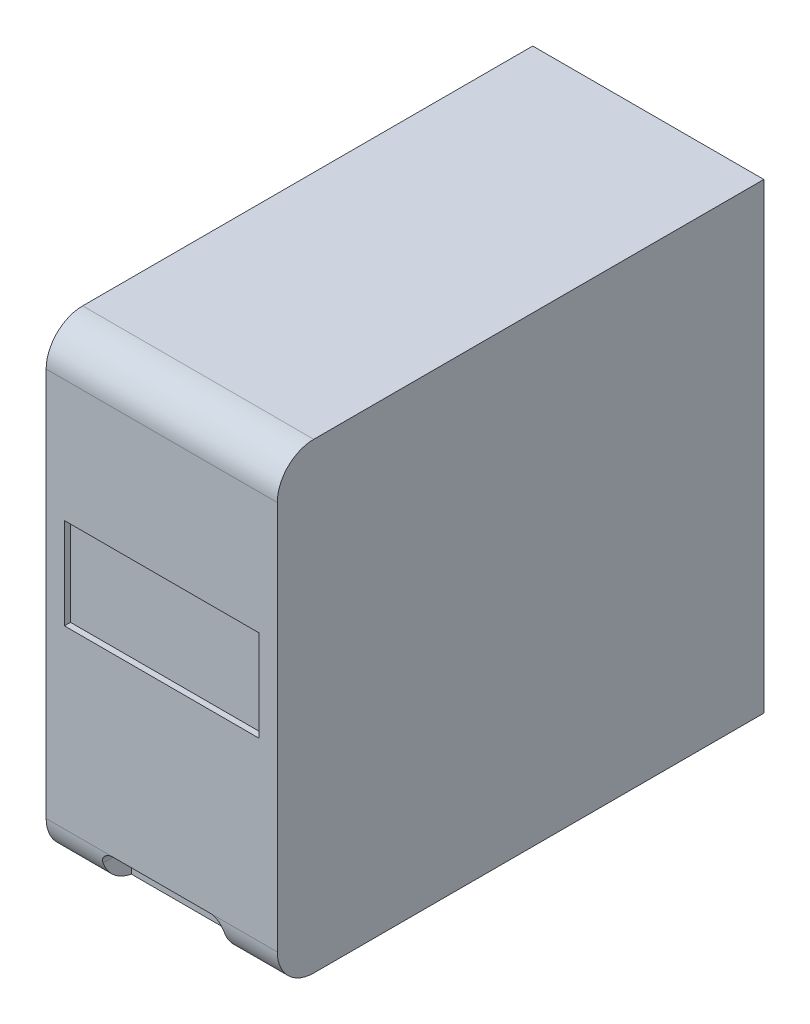
from build123d import *

# Parameters (mm, degrees)
CROQUIS1_W              = 400
CROQUIS1_H              = 380
SALIENTE_EXTRUIR1_DEPTH = 95
REDONDEO1_R             = 30
CROQUIS2_W              = 160
CROQUIS2_H              = 75
CORTAR_EXTRUIR1_DEPTH   = 5
CORTAR_EXTRUIR2_DEPTH   = 25


with BuildPart() as part:
    # Croquis1 → Saliente-Extruir1 (new body, symmetric)
    with BuildSketch(Plane(origin=(0, 0, 0), x_dir=(0, 0, -1), z_dir=(1, 0, 0))):
        Rectangle(CROQUIS1_W, CROQUIS1_H)
    extrude(amount=SALIENTE_EXTRUIR1_DEPTH, both=True)

    # Redondeo1
    redondeo1_edges = [part.edges().sort_by_distance(p)[0] for p in [
        (0, 190, 200),
        (0, -190, 200),
    ]]
    fillet(redondeo1_edges, radius=REDONDEO1_R)

    # Croquis2 → Cortar-Extruir1 (cut)
    with BuildSketch(Plane.XY.offset(200)):
        with Locations((0, 22.171988643)):
            Rectangle(CROQUIS2_W, CROQUIS2_H)
    extrude(amount=-CORTAR_EXTRUIR1_DEPTH, mode=Mode.SUBTRACT)

    # Croquis3 → Cortar-Extruir2 (cut)
    with BuildSketch(Plane.XY.offset(200)):
        with BuildLine():
            Line((40, -160), (-40, -160))
            ThreePointArc((-40, -160), (-47.071067812, -162.928932188), (-50, -170))
            Line((-50, -170), (-50, -190))
            Line((-50, -190), (50, -190))
            Line((50, -190), (50, -170))
            ThreePointArc((50, -170), (47.071067812, -162.928932188), (40, -160))
        make_face()
    extrude(amount=-CORTAR_EXTRUIR2_DEPTH, mode=Mode.SUBTRACT)


solid = part.part
